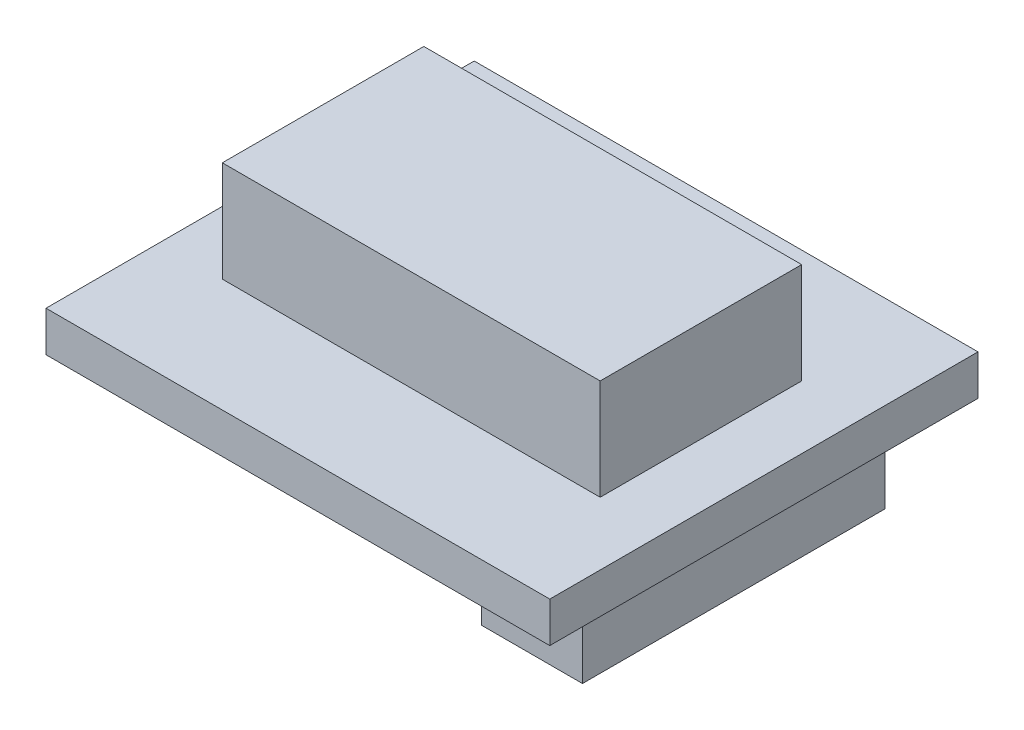
from build123d import *

# Parameters (mm, degrees)
SKETCH_1_W          = 100
SKETCH_1_H          = 85
EXTRUDE_1_DEPTH     = 8
SKETCH_2_W          = 75
SKETCH_2_H          = 40
EXTRUDE_2_DEPTH     = 20
SKETCH_3_W          = 20
SKETCH_3_H          = 60
EXTRUDE_3_DEPTH     = 15
SKETCH_4_R          = 1.6
CUT_EXTRUDE_1_DEPTH = 8


with BuildPart() as part:
    # 草图1 → 凸台-拉伸1 (new body)
    with BuildSketch(Plane(origin=(0, 0, 0), x_dir=(1, 0, 0), z_dir=(0, 1, 0))):
        Rectangle(SKETCH_1_W, SKETCH_1_H)
    extrude(amount=EXTRUDE_1_DEPTH)

    # 草图2 → 凸台-拉伸2 (add)
    with BuildSketch(Plane(origin=(0, 8, 0), x_dir=(1, 0, 0), z_dir=(0, 1, 0))):
        Rectangle(SKETCH_2_W, SKETCH_2_H)
    extrude(amount=EXTRUDE_2_DEPTH)

    # 草图3 → 凸台-拉伸3 (add)
    with BuildSketch(Plane.XZ):
        with Locations((34.768700032, 0.777091897)):
            Rectangle(SKETCH_3_W, SKETCH_3_H)
    extrude(amount=EXTRUDE_3_DEPTH)

    # 草图4 → 切除-拉伸1 (cut)
    with BuildSketch(Plane.XZ):
        with Locations((15, -12.5)):
            Circle(SKETCH_4_R)
        with Locations((15, 12.5)):
            Circle(SKETCH_4_R)
        with Locations((-35, 12.5)):
            Circle(SKETCH_4_R)
        with Locations((-35, -12.5)):
            Circle(SKETCH_4_R)
    extrude(amount=-CUT_EXTRUDE_1_DEPTH, mode=Mode.SUBTRACT)


solid = part.part
